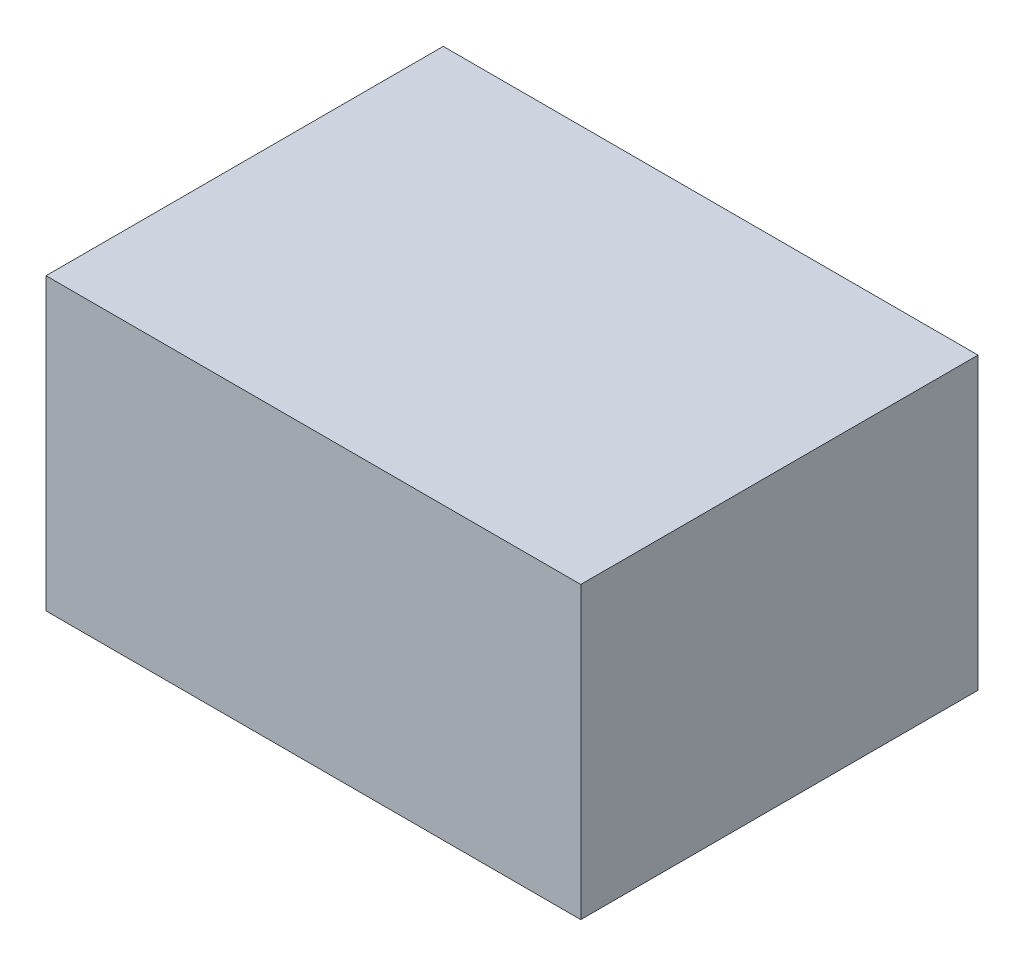
from build123d import *

# Parameters (mm, degrees)
SKETCH1_W           = 1.74999904
SKETCH1_H           = 1.29999994
BOSS_EXTRUDE1_DEPTH = 0.95000064


with BuildPart() as part:
    # Sketch1 → Boss-Extrude1 (new body)
    with BuildSketch(Plane.XZ.offset(0.47500032)):
        with Locations((0, 0.64999997)):
            Rectangle(SKETCH1_W, SKETCH1_H)
    extrude(amount=-BOSS_EXTRUDE1_DEPTH)


solid = part.part
